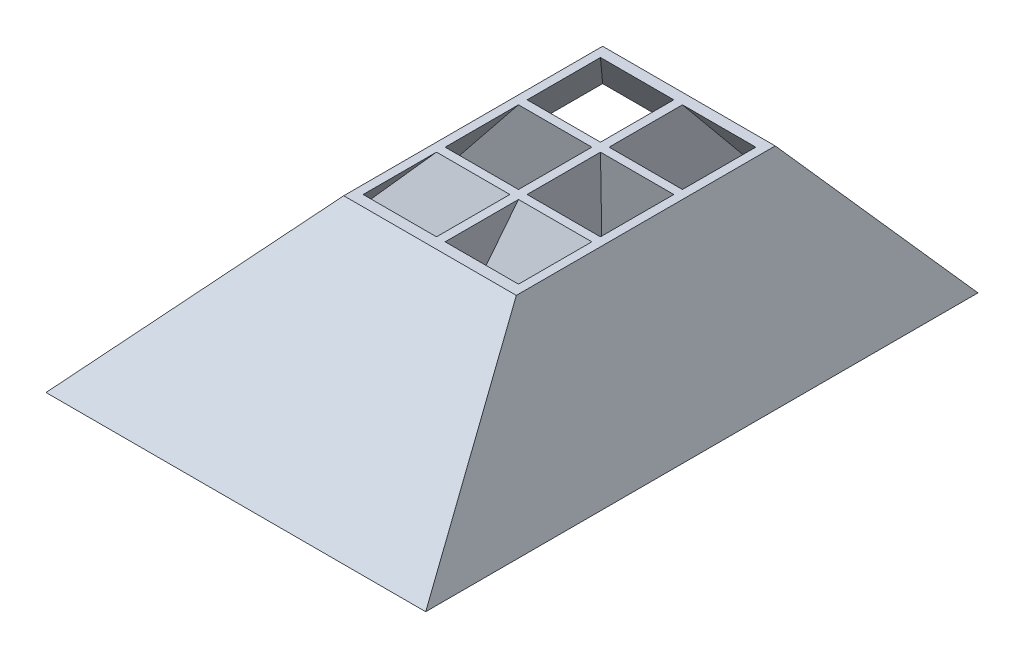
from build123d import *

# Parameters (mm, degrees)
EXTRUDE_1_DEPTH          = 64
CUT_EXTRUDE_1_DEPTH      = 73.098300123
CUT_EXTRUDE_1_DEPTH_BACK = 73.098300123


with BuildPart() as part:
    # ｽｹｯﾁ1 → ﾎﾞｽ - 押し出し1 (new body)
    with BuildSketch(Plane.XY):
        Polygon((0, 0), (44, 0), (37.501606075, 20), (17.501606075, 20), align=None)
    extrude(amount=EXTRUDE_1_DEPTH)

    # ｽｹｯﾁ2 → ｶｯﾄ - 押し出し1 (cut, two sides: drawn at the far end of the back side and taken through both)
    with BuildSketch(Plane.ZY.offset(-17.501606075).offset(-CUT_EXTRUDE_1_DEPTH_BACK)):
        Polygon((0, 0), (17, 20), (0, 20), align=None)
        Polygon((64, 0), (47, 20), (64, 20), align=None)
    extrude(amount=CUT_EXTRUDE_1_DEPTH + CUT_EXTRUDE_1_DEPTH_BACK, mode=Mode.SUBTRACT)

    # ｽｹｯﾁ4 → ｶｯﾄ - ﾛﾌﾄ1 section 0
    with BuildSketch(Plane(origin=(0, 20, 0), x_dir=(1, 0, 0), z_dir=(0, 1, 0))):
        with BuildLine():
            Line((18.501606075, -18.25), (18.501606075, -26.75))
            Line((18.501606075, -26.75), (27.001606075, -26.75))
            Line((27.001606075, -26.75), (27.001606075, -18.25))
            Line((27.001606075, -18.25), (18.501606075, -18.25))
        make_face()
    # ｽｹｯﾁ3 → ｶｯﾄ - ﾛﾌﾄ1 section 1
    with BuildSketch(Plane.XZ):
        with BuildLine():
            Line((1.25, 21.25), (1.25, 0.75))
            Line((1.25, 0.75), (21.75, 0.75))
            Line((21.75, 0.75), (21.75, 21.25))
            Line((21.75, 21.25), (1.25, 21.25))
        make_face()
    loft(mode=Mode.SUBTRACT)

    # ｽｹｯﾁ4<3> → ｶｯﾄ - ﾛﾌﾄ2 section 0
    with BuildSketch(Plane(origin=(0, 20, 0), x_dir=(1, 0, 0), z_dir=(0, 1, 0))):
        with BuildLine():
            Line((18.501606075, -27.75), (18.501606075, -36.25))
            Line((18.501606075, -36.25), (27.001606075, -36.25))
            Line((27.001606075, -36.25), (27.001606075, -27.75))
            Line((27.001606075, -27.75), (18.501606075, -27.75))
        make_face()
    # ｽｹｯﾁ3<3> → ｶｯﾄ - ﾛﾌﾄ2 section 1
    with BuildSketch(Plane.XZ):
        with BuildLine():
            Line((1.25, 42.25), (1.25, 21.75))
            Line((1.25, 21.75), (21.75, 21.75))
            Line((21.75, 21.75), (21.75, 42.25))
            Line((21.75, 42.25), (1.25, 42.25))
        make_face()
    loft(mode=Mode.SUBTRACT)

    # ｽｹｯﾁ4<4> → ｶｯﾄ - ﾛﾌﾄ3 section 0
    with BuildSketch(Plane(origin=(0, 20, 0), x_dir=(1, 0, 0), z_dir=(0, 1, 0))):
        with BuildLine():
            Line((18.501606075, -37.25), (18.501606075, -45.75))
            Line((18.501606075, -45.75), (27.001606075, -45.75))
            Line((27.001606075, -45.75), (27.001606075, -37.25))
            Line((27.001606075, -37.25), (18.501606075, -37.25))
        make_face()
    # ｽｹｯﾁ3<4> → ｶｯﾄ - ﾛﾌﾄ3 section 1
    with BuildSketch(Plane.XZ):
        with BuildLine():
            Line((1.25, 63.25), (1.25, 42.75))
            Line((1.25, 42.75), (21.75, 42.75))
            Line((21.75, 42.75), (21.75, 63.25))
            Line((21.75, 63.25), (1.25, 63.25))
        make_face()
    loft(mode=Mode.SUBTRACT)

    # ｽｹｯﾁ4<5> → ｶｯﾄ - ﾛﾌﾄ4 section 0
    with BuildSketch(Plane(origin=(0, 20, 0), x_dir=(1, 0, 0), z_dir=(0, 1, 0))):
        with BuildLine():
            Line((28.001606075, -18.25), (36.501606075, -18.25))
            Line((36.501606075, -18.25), (36.501606075, -26.75))
            Line((36.501606075, -26.75), (28.001606075, -26.75))
            Line((28.001606075, -26.75), (28.001606075, -18.25))
        make_face()
    # ｽｹｯﾁ3<5> → ｶｯﾄ - ﾛﾌﾄ4 section 1
    with BuildSketch(Plane.XZ):
        with BuildLine():
            Line((22.25, 21.25), (22.25, 0.75))
            Line((22.25, 0.75), (42.75, 0.75))
            Line((42.75, 0.75), (42.75, 21.25))
            Line((42.75, 21.25), (22.25, 21.25))
        make_face()
    loft(mode=Mode.SUBTRACT)

    # ｽｹｯﾁ4<6> → ｶｯﾄ - ﾛﾌﾄ5 section 0
    with BuildSketch(Plane(origin=(0, 20, 0), x_dir=(1, 0, 0), z_dir=(0, 1, 0))):
        with BuildLine():
            Line((28.001606075, -27.75), (28.001606075, -36.25))
            Line((28.001606075, -36.25), (36.501606075, -36.25))
            Line((36.501606075, -36.25), (36.501606075, -27.75))
            Line((36.501606075, -27.75), (28.001606075, -27.75))
        make_face()
    # ｽｹｯﾁ3<6> → ｶｯﾄ - ﾛﾌﾄ5 section 1
    with BuildSketch(Plane.XZ):
        with BuildLine():
            Line((22.25, 42.25), (22.25, 21.75))
            Line((22.25, 21.75), (42.75, 21.75))
            Line((42.75, 21.75), (42.75, 42.25))
            Line((42.75, 42.25), (22.25, 42.25))
        make_face()
    loft(mode=Mode.SUBTRACT)

    # ｽｹｯﾁ4<7> → ｶｯﾄ - ﾛﾌﾄ6 section 0
    with BuildSketch(Plane(origin=(0, 20, 0), x_dir=(1, 0, 0), z_dir=(0, 1, 0))):
        with BuildLine():
            Line((28.001606075, -37.25), (28.001606075, -45.75))
            Line((28.001606075, -45.75), (36.501606075, -45.75))
            Line((36.501606075, -45.75), (36.501606075, -37.25))
            Line((36.501606075, -37.25), (28.001606075, -37.25))
        make_face()
    # ｽｹｯﾁ3<7> → ｶｯﾄ - ﾛﾌﾄ6 section 1
    with BuildSketch(Plane.XZ):
        with BuildLine():
            Line((22.25, 63.25), (42.75, 63.25))
            Line((42.75, 63.25), (42.75, 42.75))
            Line((42.75, 42.75), (22.25, 42.75))
            Line((22.25, 42.75), (22.25, 63.25))
        make_face()
    loft(mode=Mode.SUBTRACT)


solid = part.part
